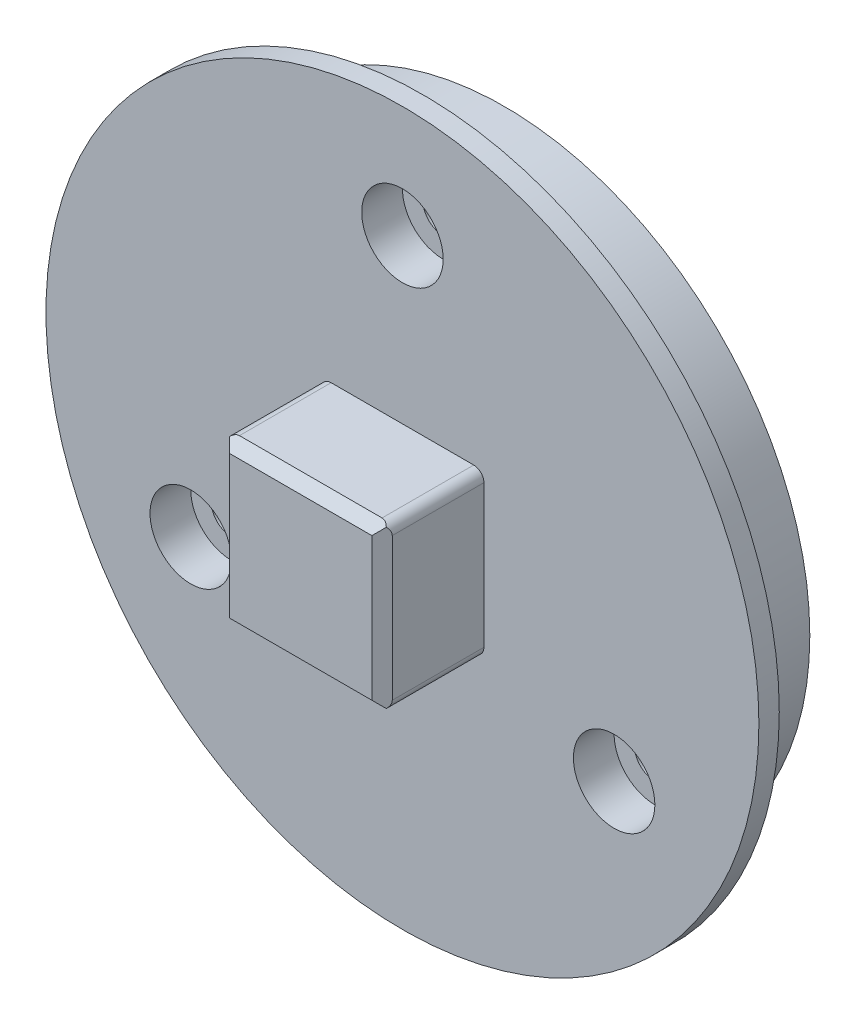
from build123d import *

# Parameters (mm, degrees)
SKETCH_1_R               = 10
EXTRUDE_1_DEPTH          = 4
SKETCH_2_R               = 11.5
EXTRUDE_2_DEPTH          = 1
SKETCH_3_R               = 10.6
EXTRUDE_3_DEPTH          = 0.4
SKETCH_9_R               = 5
CUT_EXTRUDE_5_DEPTH      = 3
SKETCH_10_R              = 12.5
SKETCH_10_R_2            = 11.5
EXTRUDE_4_DEPTH          = 1
SKETCH_11_R              = 5
SKETCH_11_R_2            = 4
EXTRUDE_5_DEPTH          = 3
SKETCH_12_R              = 4
SKETCH_12_R_2            = 2
CUT_EXTRUDE_6_DEPTH      = 1.1
SKETCH_15_R              = 17.5
EXTRUDE_7_DEPTH          = 1
SKETCH_16_R              = 15
SKETCH_16_R_2            = 4
EXTRUDE_9_DEPTH          = 4
SKETCH_17_R              = 1
CUT_EXTRUDE_8_DEPTH      = 2.6
SKETCH_18_R              = 15.5
SKETCH_18_R_2            = 15
EXTRUDE_10_DEPTH         = 0.4
SKETCH_19_R              = 1
CUT_EXTRUDE_9_DEPTH      = 3.6
CUT_EXTRUDE_9_DEPTH_BACK = 3.4
SKETCH_20_R              = 2
CUT_EXTRUDE_10_DEPTH     = 2
SKETCH_21_R              = 16.5
SKETCH_21_R_2            = 15.5
EXTRUDE_11_DEPTH         = 0.4
SKETCH_27_R              = 4
EXTRUDE_12_DEPTH         = 4
SKETCH_38_R              = 1
EXTRUDE_16_DEPTH         = 0.5
SKETCH_40_W              = 8
SKETCH_40_H              = 8
EXTRUDE_18_DEPTH         = 5
CHAMFER_1_SIZE           = 0.5
FILLET_1_R               = 0.5
SKETCH_41_R              = 2.5
CUT_EXTRUDE_11_DEPTH     = 3.1


with BuildPart() as part:
    # 草图1 → 凸台-拉伸1 (new body)
    with BuildSketch(Plane.XY):
        Circle(SKETCH_1_R)
    extrude(amount=EXTRUDE_1_DEPTH)

    # 草图2 → 凸台-拉伸2 (add)
    with BuildSketch(Plane.XY.offset(4)):
        Circle(SKETCH_2_R)
    extrude(amount=EXTRUDE_2_DEPTH)

    # 草图3 → 凸台-拉伸3 (add)
    with BuildSketch(Plane(origin=(0, 0, 4), x_dir=(-1, 0, 0), z_dir=(0, 0, -1))):
        Circle(SKETCH_3_R)
    extrude(amount=EXTRUDE_3_DEPTH)

    # 草图9 → 切除-拉伸5 (cut)
    with BuildSketch(Plane(origin=(0, 0, 0), x_dir=(-1, 0, 0), z_dir=(0, 0, -1))):
        Circle(SKETCH_9_R)
    extrude(amount=-CUT_EXTRUDE_5_DEPTH, mode=Mode.SUBTRACT)

    # 草图10 → 凸台-拉伸4 (add)
    with BuildSketch(Plane.XY.offset(5)):
        Circle(SKETCH_10_R)
        Circle(SKETCH_10_R_2, mode=Mode.SUBTRACT)
    extrude(amount=-EXTRUDE_4_DEPTH)

    # 草图11 → 凸台-拉伸5 (add)
    with BuildSketch(Plane(origin=(0, 0, 3), x_dir=(-1, 0, 0), z_dir=(0, 0, -1))):
        Circle(SKETCH_11_R)
        Circle(SKETCH_11_R_2, mode=Mode.SUBTRACT)
    extrude(amount=EXTRUDE_5_DEPTH)

    # 草图12 → 切除-拉伸6 (cut)
    with BuildSketch(Plane(origin=(0, 0, 3), x_dir=(-1, 0, 0), z_dir=(0, 0, -1))):
        Circle(SKETCH_12_R)
        Circle(SKETCH_12_R_2, mode=Mode.SUBTRACT)
    extrude(amount=-CUT_EXTRUDE_6_DEPTH, mode=Mode.SUBTRACT)

    # 草图15 → 凸台-拉伸7 (add)
    with BuildSketch(Plane.XY.offset(5)):
        Circle(SKETCH_15_R)
    extrude(amount=-EXTRUDE_7_DEPTH)

    # 草图16 → 凸台-拉伸9 (add)
    with BuildSketch(Plane(origin=(0, 0, 4), x_dir=(-1, 0, 0), z_dir=(0, 0, -1))):
        Circle(SKETCH_16_R)
        Circle(SKETCH_16_R_2, mode=Mode.SUBTRACT)
    extrude(amount=EXTRUDE_9_DEPTH)

    # 草图17 → 切除-拉伸8 (cut)
    with BuildSketch(Plane(origin=(0, 0, 0), x_dir=(-1, 0, 0), z_dir=(0, 0, -1))):
        with Locations((0, 12)):
            Circle(SKETCH_17_R)
        with Locations((10.392304845, 6)):
            Circle(SKETCH_17_R)
        with Locations((10.392304845, -6)):
            Circle(SKETCH_17_R)
        with Locations((0, -12)):
            Circle(SKETCH_17_R)
        with Locations((-10.392304845, -6)):
            Circle(SKETCH_17_R)
        with Locations((-10.392304845, 6)):
            Circle(SKETCH_17_R)
    extrude(amount=-CUT_EXTRUDE_8_DEPTH, mode=Mode.SUBTRACT)

    # 草图18 → 凸台-拉伸10 (add)
    with BuildSketch(Plane(origin=(0, 0, 4), x_dir=(-1, 0, 0), z_dir=(0, 0, -1))):
        Circle(SKETCH_18_R)
        Circle(SKETCH_18_R_2, mode=Mode.SUBTRACT)
    extrude(amount=EXTRUDE_10_DEPTH)

    # 草图19 → 切除-拉伸9 (cut, two sides)
    with BuildSketch(Plane(origin=(0, 0, 2.6), x_dir=(-1, 0, 0), z_dir=(0, 0, -1))) as cut_extrude_9_sk:
        with Locations((0, 12)):
            Circle(SKETCH_19_R)
        with Locations((10.392304845, -6)):
            Circle(SKETCH_19_R)
        with Locations((-10.392304845, -6)):
            Circle(SKETCH_19_R)
    extrude(amount=CUT_EXTRUDE_9_DEPTH, mode=Mode.SUBTRACT)
    extrude(cut_extrude_9_sk.sketch, amount=-CUT_EXTRUDE_9_DEPTH_BACK, mode=Mode.SUBTRACT)

    # 草图20 → 切除-拉伸10 (cut)
    with BuildSketch(Plane.XY.offset(5)):
        with Locations((0, 12)):
            Circle(SKETCH_20_R)
        with Locations((10.392304845, -6)):
            Circle(SKETCH_20_R)
        with Locations((-10.392304845, -6)):
            Circle(SKETCH_20_R)
    extrude(amount=-CUT_EXTRUDE_10_DEPTH, mode=Mode.SUBTRACT)

    # 草图21 → 凸台-拉伸11 (add)
    with BuildSketch(Plane(origin=(0, 0, 3.6), x_dir=(-1, 0, 0), z_dir=(0, 0, -1))):
        Circle(SKETCH_21_R)
        Circle(SKETCH_21_R_2, mode=Mode.SUBTRACT)
    extrude(amount=-EXTRUDE_11_DEPTH)

    # 草图27 → 凸台-拉伸12 (add)
    with BuildSketch(Plane(origin=(0, 0, 0), x_dir=(-1, 0, 0), z_dir=(0, 0, -1))):
        Circle(SKETCH_27_R)
    extrude(amount=-EXTRUDE_12_DEPTH)

    # 草图38 → 凸台-拉伸16 (add)
    with BuildSketch(Plane(origin=(0, 0, 2.6), x_dir=(-1, 0, 0), z_dir=(0, 0, -1))):
        with Locations((10.392304845, 6)):
            Circle(SKETCH_38_R)
        with Locations((0, -12)):
            Circle(SKETCH_38_R)
        with Locations((-10.392304845, 6)):
            Circle(SKETCH_38_R)
    extrude(amount=EXTRUDE_16_DEPTH)

    # 草图40 → 凸台-拉伸18 (add)
    with BuildSketch(Plane.XY.offset(5)):
        Rectangle(SKETCH_40_W, SKETCH_40_H)
    extrude(amount=EXTRUDE_18_DEPTH)

    # 倒角1
    chamfer_1_edges = [part.edges().sort_by_distance(p)[0] for p in [
        (-4, 0, 10),
        (0, -4, 10),
        (4, 0, 10),
        (0, 4, 10),
    ]]
    chamfer(chamfer_1_edges, length=CHAMFER_1_SIZE)

    # 圆角1
    fillet_1_edges = [part.edges().sort_by_distance(p)[0] for p in [
        (-4, 4, 7.25),
        (4, 4, 7.25),
        (4, -4, 7.25),
        (-4, -4, 7.25),
    ]]
    fillet(fillet_1_edges, radius=FILLET_1_R)

    # 草图41 → 切除-拉伸11 (cut)
    with BuildSketch(Plane(origin=(0, 0, 0), x_dir=(-1, 0, 0), z_dir=(0, 0, -1))):
        Circle(SKETCH_41_R)
    extrude(amount=-CUT_EXTRUDE_11_DEPTH, mode=Mode.SUBTRACT)


solid = part.part
